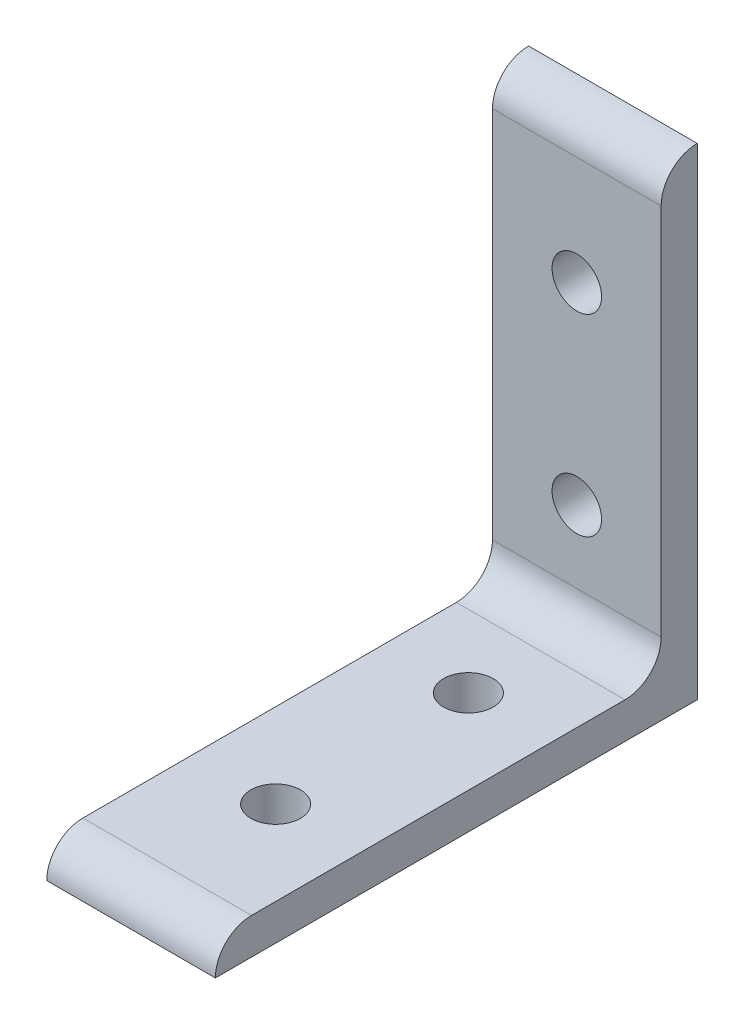
from build123d import *

# Parameters (mm, degrees)
BOSS_EXTRUDE1_DEPTH      = 22.225
M6_CLEARANCE_HOLE1_D     = 6.5278
M6_CLEARANCE_HOLE1_DEPTH = 63.5
M6_CLEARANCE_HOLE2_D     = 6.5278
M6_CLEARANCE_HOLE2_DEPTH = 63.5
FILLET1_R                = 4.7625


with BuildPart() as part:
    # Sketch1 → Boss-Extrude1 (new body)
    with BuildSketch(Plane(origin=(11.1125, 0, 0), x_dir=(0, 0, -1), z_dir=(1, 0, 0))):
        with BuildLine():
            Line((-4.767789963, 58.742792373), (-4.767789963, 4.767792373))
            Line((-4.767789963, 4.767792373), (-58.742789963, 4.767792373))
            ThreePointArc((-58.742789963, 4.767792373), (-62.110386009, 3.372888418), (-63.505289963, 0.005292373))
            Line((-63.505289963, 0.005292373), (-0.005289963, 0.005292373))
            Line((-0.005289963, 0.005292373), (-0.005289963, 63.505292373))
            ThreePointArc((-0.005289963, 63.505292373), (-3.372886009, 62.110388418), (-4.767789963, 58.742792373))
        make_face()
    extrude(amount=-BOSS_EXTRUDE1_DEPTH)

    # M6 Clearance Hole1
    with Locations(Plane.XZ.offset(-0.005292373)):
        with Locations((0, 19.055289963), (0, 44.455289963)):
            Hole(M6_CLEARANCE_HOLE1_D / 2, depth=M6_CLEARANCE_HOLE1_DEPTH)

    # M6 Clearance Hole2
    with Locations(Plane(origin=(0, 0, 0.005289963), x_dir=(-1, 0, 0), z_dir=(0, 0, -1))):
        with Locations((0, 19.055292373), (0, 44.455292373)):
            Hole(M6_CLEARANCE_HOLE2_D / 2, depth=M6_CLEARANCE_HOLE2_DEPTH)

    # Fillet1
    fillet1_edges = [part.edges().sort_by_distance(p)[0] for p in [
        (0, 4.767792373, 4.767789963),
    ]]
    fillet(fillet1_edges, radius=FILLET1_R)


solid = part.part
